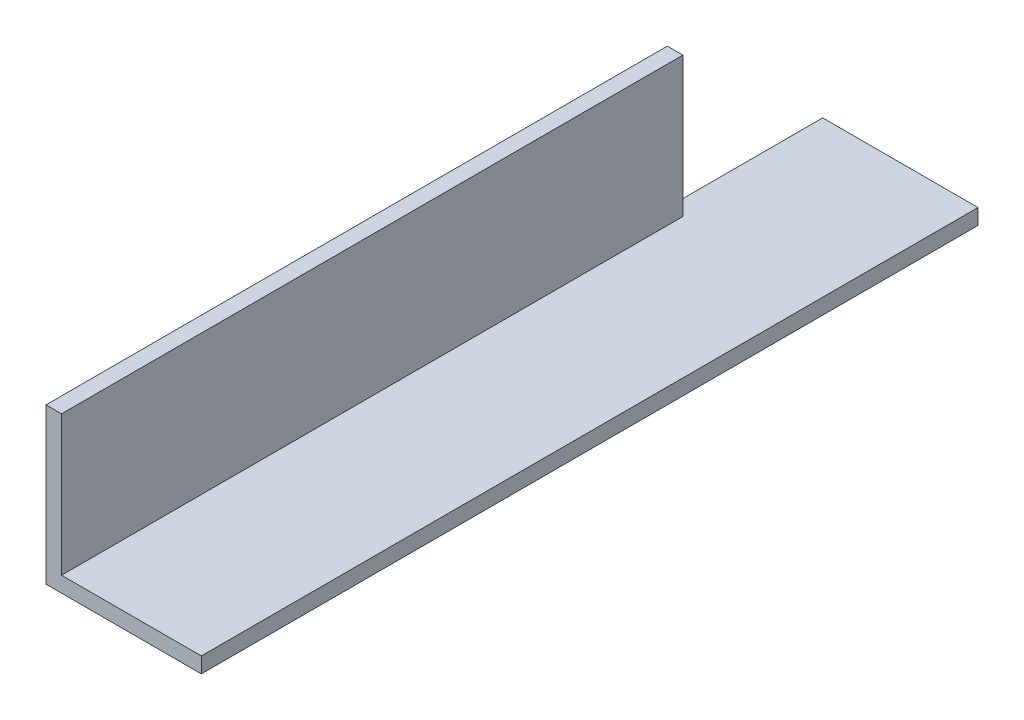
from build123d import *

# Parameters (mm, degrees)
BOSS_EXTRUDE1_DEPTH = 100
SKETCH2_W           = 20
SKETCH2_H           = 18
CUT_EXTRUDE1_DEPTH  = 3


with BuildPart() as part:
    # Sketch1 → Boss-Extrude1 (new body)
    with BuildSketch(Plane.XY):
        Polygon((0, 0), (0, 20), (2, 20), (2, 2), (20, 2), (20, 0), align=None)
    extrude(amount=BOSS_EXTRUDE1_DEPTH)

    # Sketch2 → Cut-Extrude1 (cut, through all)
    with BuildSketch(Plane(origin=(2, 0, 0), x_dir=(0, 0, -1), z_dir=(1, 0, 0))):
        with Locations((-10, 11)):
            Rectangle(SKETCH2_W, SKETCH2_H)
    extrude(amount=-CUT_EXTRUDE1_DEPTH, mode=Mode.SUBTRACT)


solid = part.part
